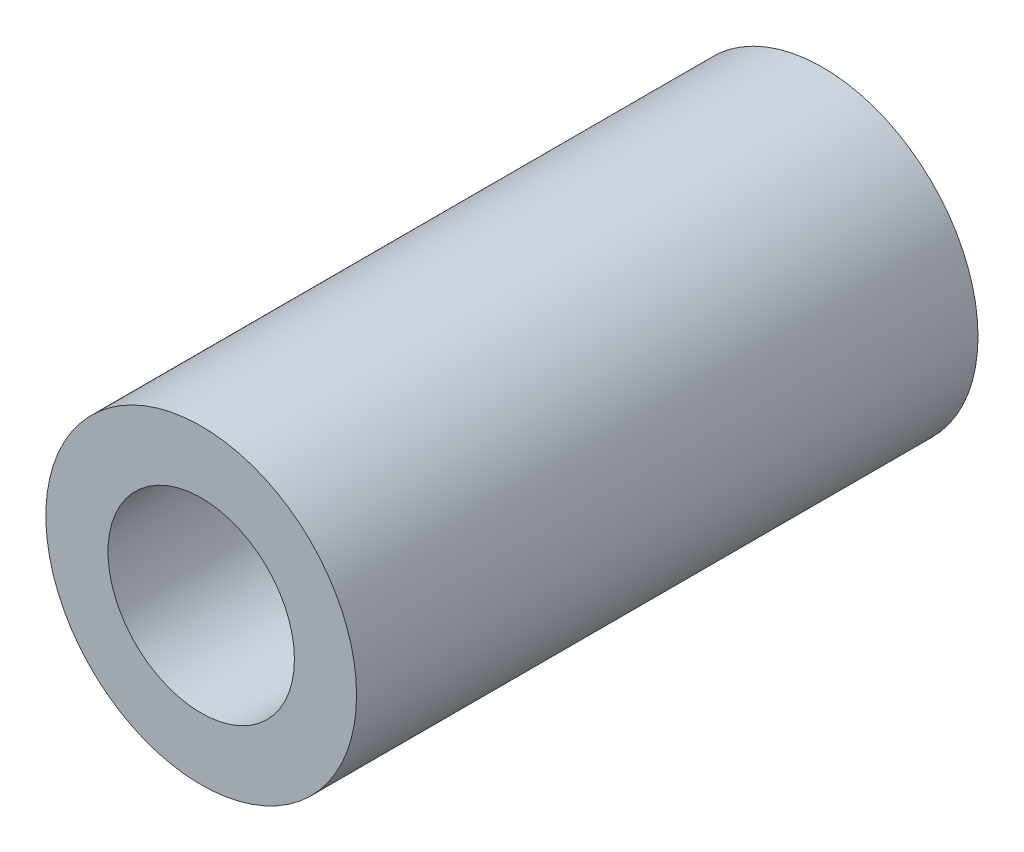
from build123d import *

# Parameters (mm, degrees)
SKETCH1_R           = 2.5
BOSS_EXTRUDE1_DEPTH = 10
SKETCH2_R           = 1.5
CUT_EXTRUDE1_DEPTH  = 10


with BuildPart() as part:
    # Sketch1 → Boss-Extrude1 (new body)
    with BuildSketch(Plane.XY):
        Circle(SKETCH1_R)
    extrude(amount=BOSS_EXTRUDE1_DEPTH)

    # Sketch2 → Cut-Extrude1 (cut)
    with BuildSketch(Plane.XY.offset(10)):
        Circle(SKETCH2_R)
    extrude(amount=-CUT_EXTRUDE1_DEPTH, mode=Mode.SUBTRACT)


solid = part.part
